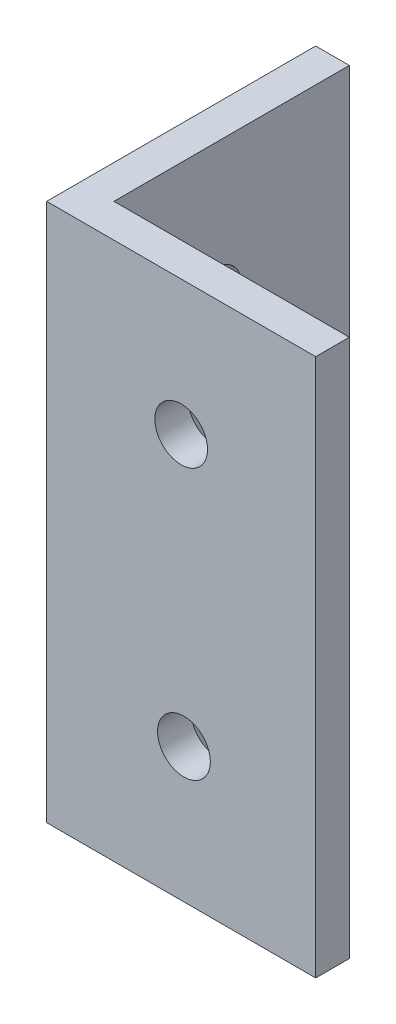
from build123d import *

# Parameters (mm, degrees)
EXTRUDE_THIN1_DEPTH            = 50.8
F_9_0_196_DIAMETER_HOLE1_D     = 4.9784
F_9_0_196_DIAMETER_HOLE1_DEPTH = 3.176


with BuildPart() as part:
    # Sketch1 → Extrude-Thin1 (new body)
    with BuildSketch(Plane(origin=(0, 0, 0), x_dir=(1, 0, 0), z_dir=(0, 1, 0))):
        Polygon((25.4, 0), (0, 0), (0, 25.4), (3.175, 25.4), (3.175, 3.175), (25.4, 3.175), align=None)
    extrude(amount=EXTRUDE_THIN1_DEPTH)

    # #9 (0.196) Diameter Hole1
    with Locations(Plane(origin=(0, 0, -3.175), x_dir=(-1, 0, 0), z_dir=(0, 0, -1))):
        with Locations((-12.960193373, 12.7), (-12.7, 38.1)):
            f_9_0_196_diameter_hole1 = Hole(F_9_0_196_DIAMETER_HOLE1_D / 2, depth=F_9_0_196_DIAMETER_HOLE1_DEPTH)

    # Mirror1: #9 (0.196) Diameter Hole1 across plane
    add(f_9_0_196_diameter_hole1.mirror(Plane(origin=(0, 0, 0), x_dir=(-0.707106781, 0, 0.707106781), z_dir=(-0.707106781, 0, -0.707106781))), mode=Mode.SUBTRACT)


solid = part.part
